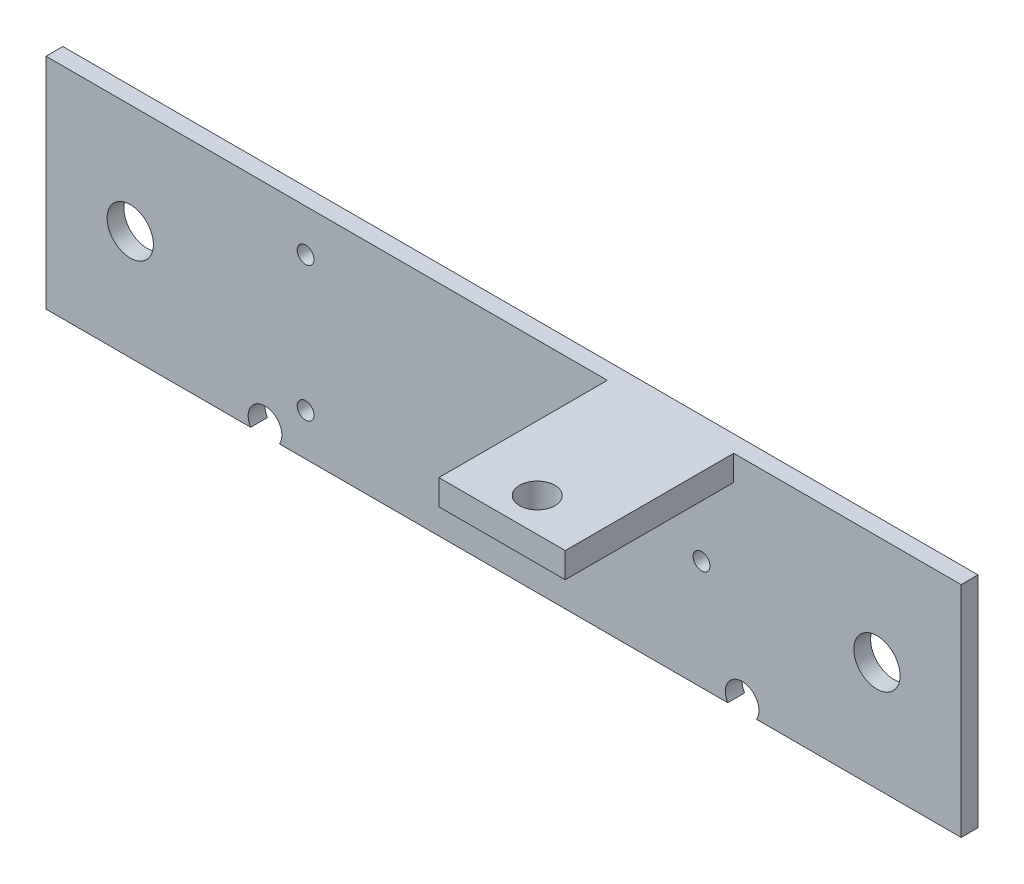
from build123d import *

# Parameters (mm, degrees)
SKETCH1_W           = 108.64
SKETCH1_H           = 26
SKETCH1_R           = 1
SKETCH1_R_2         = 2.75
BOSS_EXTRUDE1_DEPTH = 2
CUT_EXTRUDE2_REACH  = 4
SKETCH5_R           = 2
SKETCH3_W           = 15
SKETCH3_H           = 3
BOSS_EXTRUDE2_DEPTH = 20
SKETCH4_R           = 2.1
CUT_EXTRUDE1_DEPTH  = 15


with BuildPart() as part:
    # Sketch1 → Boss-Extrude1 (new body)
    with BuildSketch(Plane.XY):
        with Locations((54.32, 13)):
            Rectangle(SKETCH1_W, SKETCH1_H)
        with Locations((30.82, 21)):
            Circle(SKETCH1_R, mode=Mode.SUBTRACT)
        with Locations((30.82, 5)):
            Circle(SKETCH1_R, mode=Mode.SUBTRACT)
        with Locations((77.82, 13)):
            Circle(SKETCH1_R, mode=Mode.SUBTRACT)
        with Locations((10, 13)):
            Circle(SKETCH1_R_2, mode=Mode.SUBTRACT)
        with Locations((98.64, 13)):
            Circle(SKETCH1_R_2, mode=Mode.SUBTRACT)
    extrude(amount=BOSS_EXTRUDE1_DEPTH)

    # Sketch5 → Cut-Extrude2 (cut, up to next)
    with BuildSketch(Plane.XY.offset(2), mode=Mode.PRIVATE) as cut_extrude2_sk1:
        with Locations((26, 1.043474904)):
            Circle(SKETCH5_R)
    cut_extrude2_tool1 = extrude(cut_extrude2_sk1.sketch, amount=-CUT_EXTRUDE2_REACH, mode=Mode.PRIVATE) & part.part
    add(cut_extrude2_tool1.solids().sort_by_distance((26, 1.043475, 2))[0], mode=Mode.SUBTRACT)
    # Sketch5 → Cut-Extrude2 (cut, up to next)
    with BuildSketch(Plane.XY.offset(2), mode=Mode.PRIVATE) as cut_extrude2_sk2:
        with Locations((82.64, 1.043474904)):
            Circle(SKETCH5_R)
    cut_extrude2_tool2 = extrude(cut_extrude2_sk2.sketch, amount=-CUT_EXTRUDE2_REACH, mode=Mode.PRIVATE) & part.part
    add(cut_extrude2_tool2.solids().sort_by_distance((82.64, 1.043475, 2))[0], mode=Mode.SUBTRACT)

    # Sketch3 → Boss-Extrude2 (add)
    with BuildSketch(Plane.XY.offset(2)):
        with Locations((74.14, 24.5)):
            Rectangle(SKETCH3_W, SKETCH3_H)
    extrude(amount=BOSS_EXTRUDE2_DEPTH)

    # Sketch4 → Cut-Extrude1 (cut)
    with BuildSketch(Plane(origin=(0, 26, 0), x_dir=(1, 0, 0), z_dir=(0, 1, 0))):
        with Locations((74.32, -18)):
            Circle(SKETCH4_R)
    extrude(amount=-CUT_EXTRUDE1_DEPTH, mode=Mode.SUBTRACT)


solid = part.part
